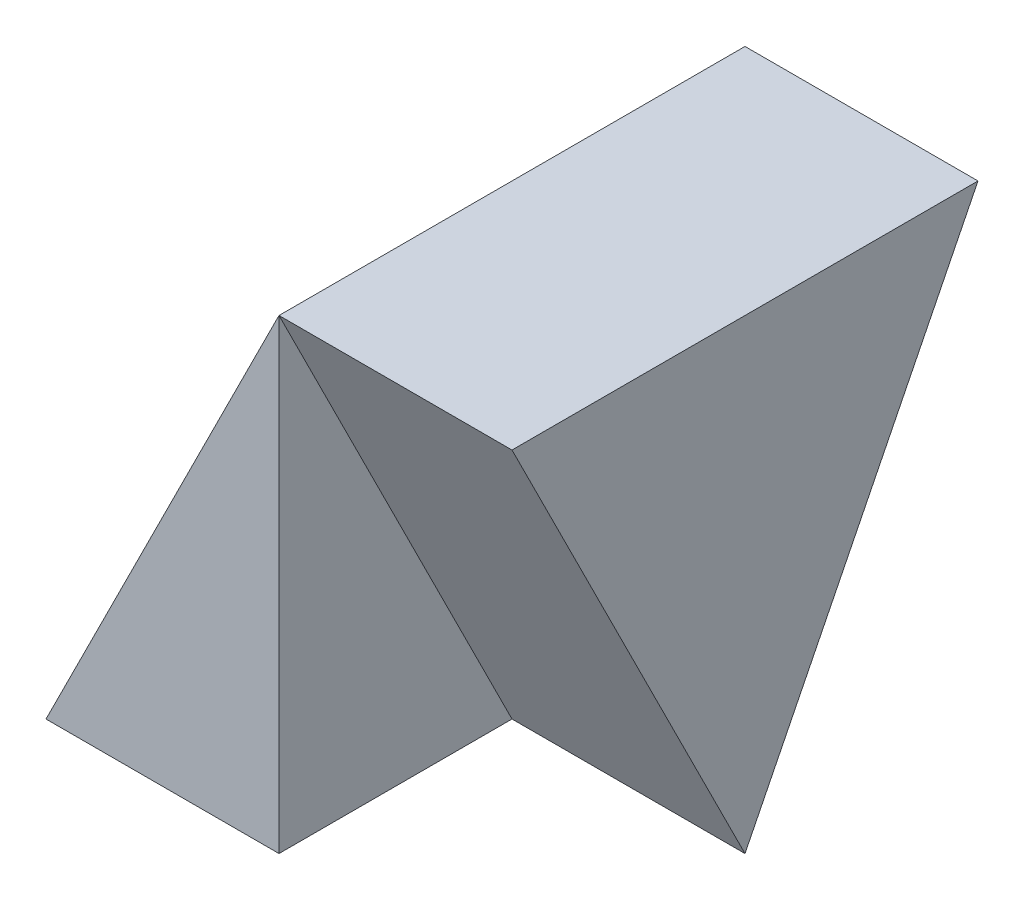
from build123d import *

# Parameters (mm, degrees)
SKETCH1_W           = 40
SKETCH1_H           = 40
BOSS_EXTRUDE1_DEPTH = 40
CUT_EXTRUDE1_DEPTH  = 40
CUT_EXTRUDE3_DEPTH  = 20


with BuildPart() as part:
    # Sketch1 → Boss-Extrude1 (new body)
    with BuildSketch(Plane.XY):
        with Locations((20, 20)):
            Rectangle(SKETCH1_W, SKETCH1_H)
    extrude(amount=BOSS_EXTRUDE1_DEPTH)

    # Sketch2 → Cut-Extrude1 (cut)
    with BuildSketch(Plane.XY.offset(40)):
        Polygon((0, 0), (20, 40), (0, 40), align=None)
    extrude(amount=-CUT_EXTRUDE1_DEPTH, mode=Mode.SUBTRACT)

    # Sketch3 → Cut-Extrude3 (cut)
    with BuildSketch(Plane(origin=(40, 0, 0), x_dir=(0, 0, -1), z_dir=(1, 0, 0))):
        Polygon((-40, 40), (-40, 0), (-30, 20), align=None)
        Polygon((-30, 20), (-40, 0), (-20, 0), align=None)
        Polygon((-10, 20), (0, 0), (0, 40), align=None)
        Polygon((-10, 20), (-20, 0), (0, 0), align=None)
    extrude(amount=-CUT_EXTRUDE3_DEPTH, mode=Mode.SUBTRACT)


solid = part.part
